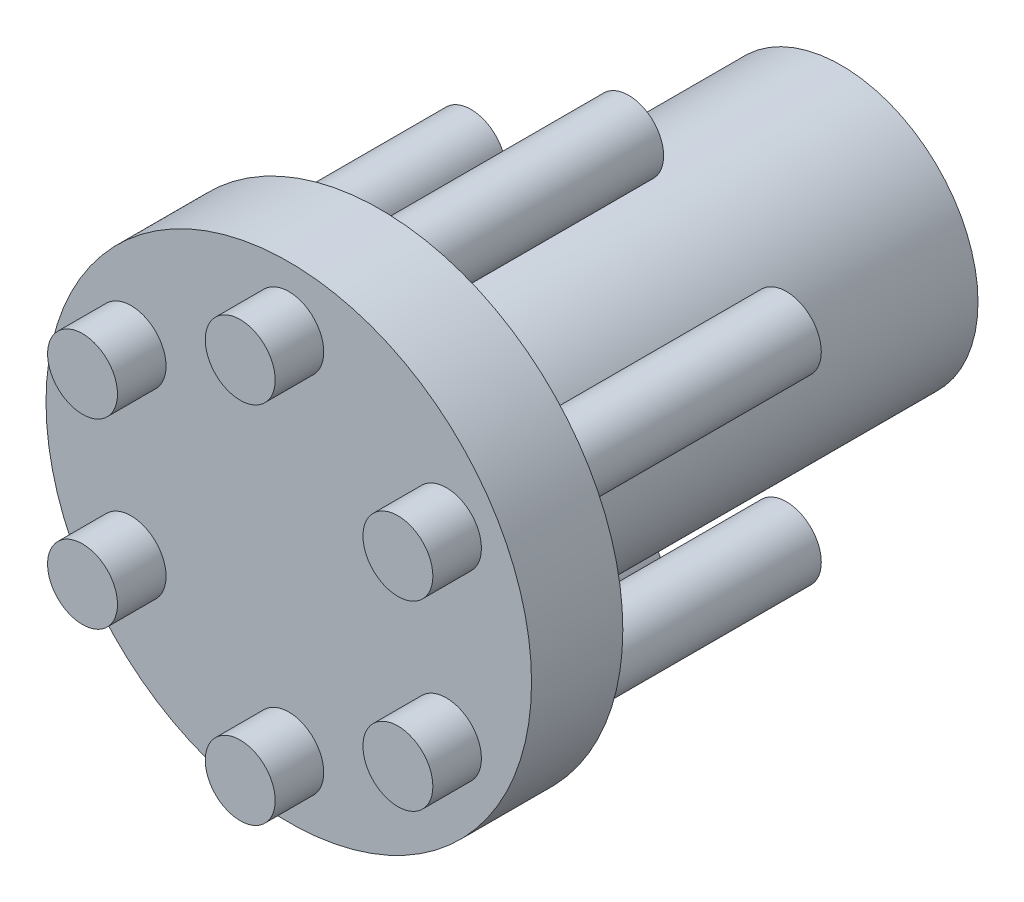
from build123d import *

# Parameters (mm, degrees)
SKETCH1_R                = 12.7
BOSS_EXTRUDE1_DEPTH      = 4.7752
SKETCH2_R                = 7.1501
BOSS_EXTRUDE2_DEPTH      = 24.13
SKETCH3_R                = 1.8288
BOSS_EXTRUDE3_DEPTH      = 2.54
BOSS_EXTRUDE3_DEPTH_BACK = 17.78


with BuildPart() as part:
    # Sketch1 → Boss-Extrude1 (new body)
    with BuildSketch(Plane.XY):
        Circle(SKETCH1_R)
    extrude(amount=BOSS_EXTRUDE1_DEPTH)

    # Sketch2 → Boss-Extrude2 (add)
    with BuildSketch(Plane(origin=(0, 0, 0), x_dir=(-1, 0, 0), z_dir=(0, 0, -1))):
        Circle(SKETCH2_R)
    extrude(amount=BOSS_EXTRUDE2_DEPTH)

    # Sketch3 → Boss-Extrude3 (add, two sides)
    with BuildSketch(Plane.XY.offset(4.7752)) as boss_extrude3_sk:
        with Locations((0, 9.525)):
            Circle(SKETCH3_R)
        with Locations((8.248891971, 4.7625)):
            Circle(SKETCH3_R)
        with Locations((8.248891971, -4.7625)):
            Circle(SKETCH3_R)
        with Locations((0, -9.525)):
            Circle(SKETCH3_R)
        with Locations((-8.248891971, -4.7625)):
            Circle(SKETCH3_R)
        with Locations((-8.248891971, 4.7625)):
            Circle(SKETCH3_R)
    extrude(amount=BOSS_EXTRUDE3_DEPTH)
    extrude(boss_extrude3_sk.sketch, amount=-BOSS_EXTRUDE3_DEPTH_BACK)


solid = part.part
